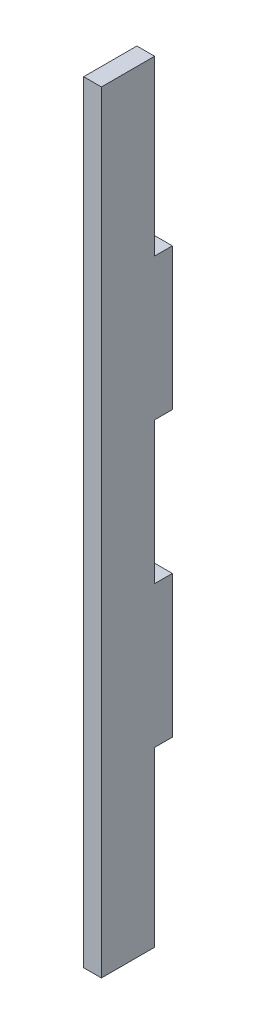
from build123d import *

# Parameters (mm, degrees)
BOSS_EXTRUDE1_DEPTH = 3.175


with BuildPart() as part:
    # Sketch1 → Boss-Extrude1 (new body)
    with BuildSketch(Plane(origin=(0, 0, 0), x_dir=(0, 0, -1), z_dir=(1, 0, 0))):
        Polygon((-6.35, -132.588), (3.175, -132.588), (3.175, -101.6), (6.35, -101.6), (6.35, -76.2), (3.175, -76.2), (3.175, -50.8), (6.35, -50.8), (6.35, -25.4), (3.175, -25.4), (3.175, 5.588), (-6.35, 5.588), align=None)
    extrude(amount=BOSS_EXTRUDE1_DEPTH)


solid = part.part
